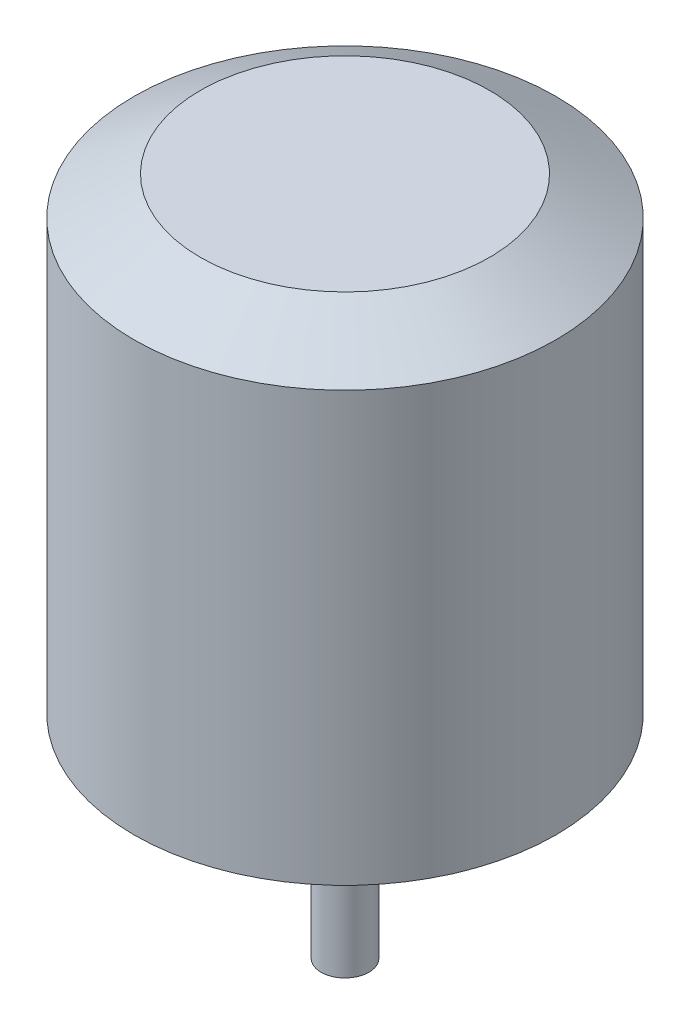
from build123d import *

# Parameters (mm, degrees)
SKETCH1_R           = 14
BOSS_EXTRUDE1_DEPTH = 15.5
CHAMFER1_SIZE       = 2.54
CHAMFER1_SIZE2      = 4.399409051
SKETCH2_R           = 1.5875
BOSS_EXTRUDE2_DEPTH = 14.1


with BuildPart() as part:
    # Sketch1 → Boss-Extrude1 (new body, symmetric)
    with BuildSketch(Plane(origin=(0, 0, 0), x_dir=(1, 0, 0), z_dir=(0, 1, 0))):
        Circle(SKETCH1_R)
    extrude(amount=BOSS_EXTRUDE1_DEPTH, both=True)

    # Chamfer1
    chamfer1_edges = [part.edges().sort_by_distance(p)[0] for p in [
        (-14, 15.5, 0),
    ]]
    chamfer1_side = [part.faces().sort_by_distance(p)[0] for p in [
        (-14, 0, 0),
    ]]
    chamfer(chamfer1_edges, length=CHAMFER1_SIZE, length2=CHAMFER1_SIZE2, reference=chamfer1_side[0])

    # Sketch2 → Boss-Extrude2 (add)
    with BuildSketch(Plane.XZ.offset(15.5)):
        Circle(SKETCH2_R)
    extrude(amount=BOSS_EXTRUDE2_DEPTH)


solid = part.part
